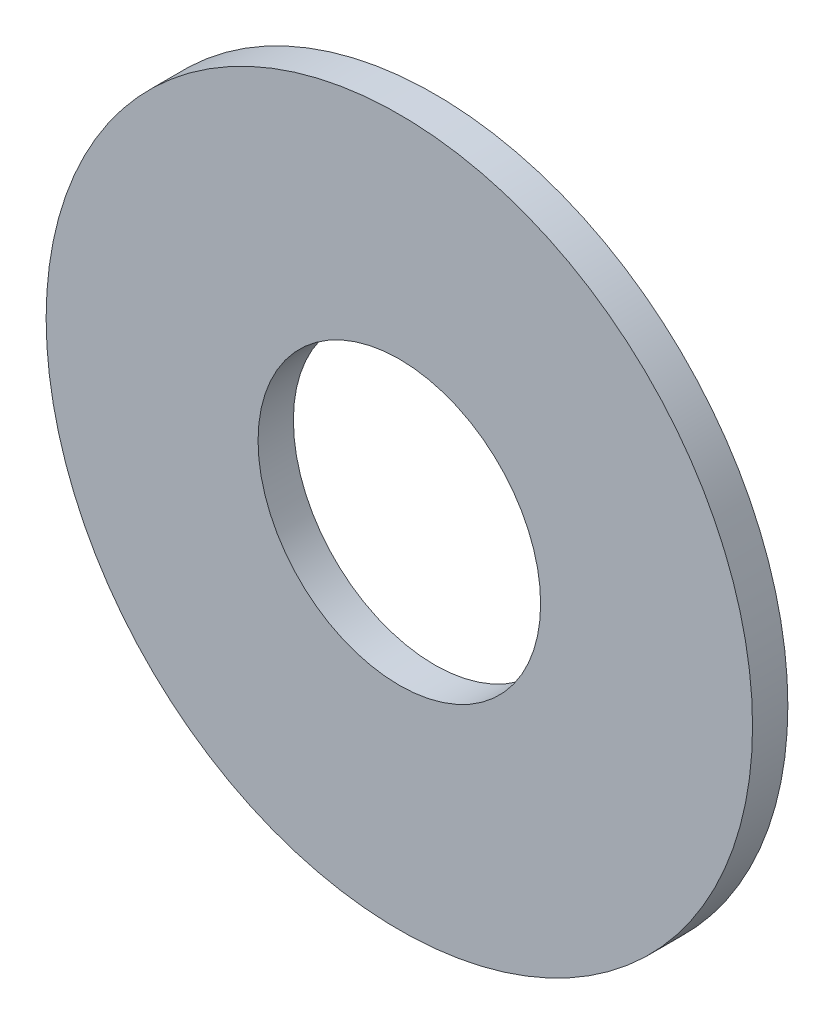
from build123d import *

# Parameters (mm, degrees)
ESBO_O1_R                = 10
ESBO_O1_R_2              = 4
RESSALTO_EXTRUS_O1_DEPTH = 1


with BuildPart() as part:
    # Esboço1 → Ressalto-extrusão1 (new body)
    with BuildSketch(Plane.XY):
        Circle(ESBO_O1_R)
        Circle(ESBO_O1_R_2, mode=Mode.SUBTRACT)
    extrude(amount=RESSALTO_EXTRUS_O1_DEPTH)


solid = part.part
